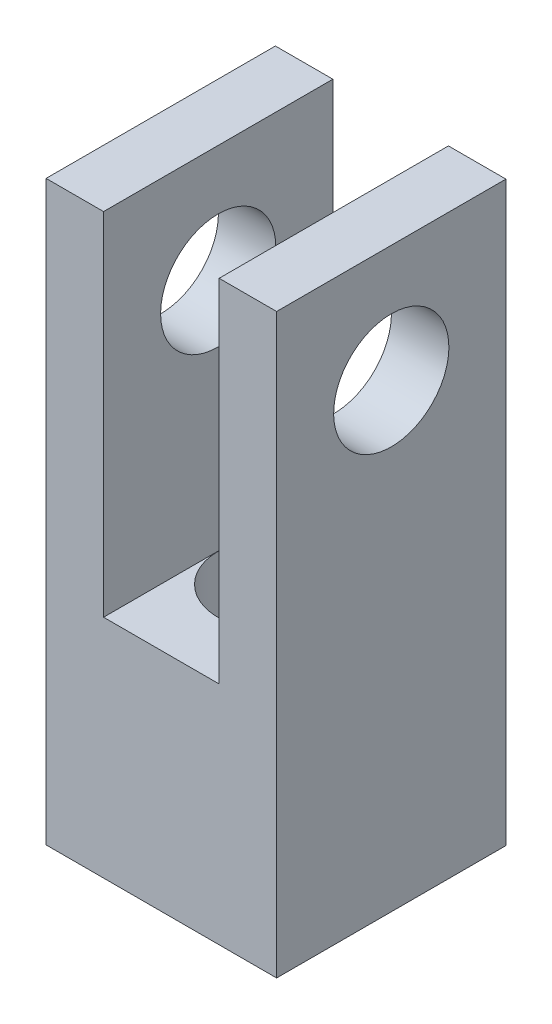
from build123d import *

# Parameters (mm, degrees)
BOSS_EXTRUDE1_DEPTH = 4.7371
CUT_EXTRUDE1_REACH  = 25.851
SKETCH4_R           = 2.38125
SKETCH5_R           = 2.38125
CUT_EXTRUDE2_DEPTH  = 10.525


with BuildPart() as part:
    # Sketch3 → Boss-Extrude1 (new body, symmetric)
    with BuildSketch(Plane.XY):
        Polygon((2.3876, -9.68375), (-2.3876, -9.68375), (-2.3876, 4.83235), (-4.7625, 4.83235), (-4.7625, -19.01825), (4.7625, -19.01825), (4.7625, 4.83235), (2.3876, 4.83235), align=None)
    extrude(amount=BOSS_EXTRUDE1_DEPTH, both=True)

    # Sketch4 → Cut-Extrude1 (cut, up to next)
    with BuildSketch(Plane.XZ.offset(19.01825), mode=Mode.PRIVATE) as cut_extrude1_sk1:
        Circle(SKETCH4_R)
    cut_extrude1_tool1 = extrude(cut_extrude1_sk1.sketch, amount=-CUT_EXTRUDE1_REACH, mode=Mode.PRIVATE) & part.part
    add(cut_extrude1_tool1.solids().sort_by_distance((0, -19.01825, 0))[0], mode=Mode.SUBTRACT)

    # Sketch5 → Cut-Extrude2 (cut, through all)
    with BuildSketch(Plane(origin=(4.7625, 0, 0), x_dir=(0, 0, -1), z_dir=(1, 0, 0))):
        Circle(SKETCH5_R)
    extrude(amount=-CUT_EXTRUDE2_DEPTH, mode=Mode.SUBTRACT)


solid = part.part
